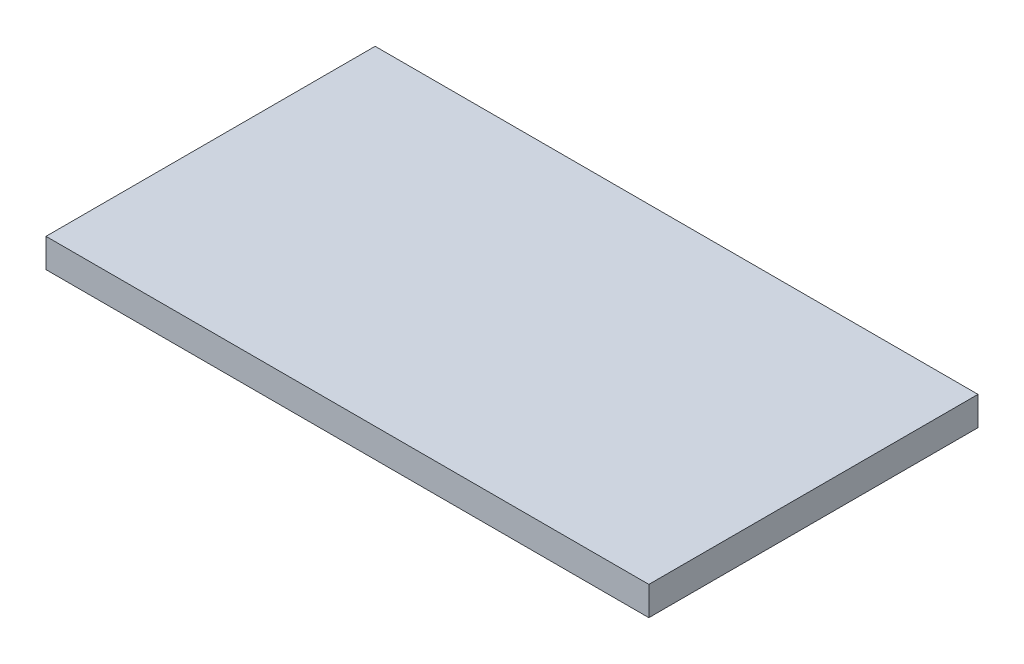
from build123d import *

# Parameters (mm, degrees)
SKETCH1_W           = 52.2
SKETCH1_H           = 28.5
SKETCH1_R           = 1
SKETCH1_W_2         = 35.320636832
SKETCH1_H_2         = 5.8
BOSS_EXTRUDE1_DEPTH = 2.5
SKETCH2_W           = 52.2
SKETCH2_H           = 28.5
BOSS_EXTRUDE2_DEPTH = 2.5


with BuildPart() as part:
    # Sketch1 → Boss-Extrude1 (new body)
    with BuildSketch(Plane(origin=(0, 0, 0), x_dir=(1, 0, 0), z_dir=(0, 1, 0))):
        with Locations((0, 2.55)):
            Rectangle(SKETCH1_W, SKETCH1_H)
        with Locations((-22.8, -3.2)):
            Circle(SKETCH1_R, mode=Mode.SUBTRACT)
        with Locations((22.8, -3.2)):
            Circle(SKETCH1_R, mode=Mode.SUBTRACT)
        with Locations((22.8, 8.3)):
            Circle(SKETCH1_R, mode=Mode.SUBTRACT)
        with Locations((-22.8, 8.3)):
            Circle(SKETCH1_R, mode=Mode.SUBTRACT)
        with Locations((0, -4.8)):
            Rectangle(SKETCH1_W_2, SKETCH1_H_2, mode=Mode.SUBTRACT)
        with Locations((0, 9.9)):
            Rectangle(SKETCH1_W_2, SKETCH1_H_2, mode=Mode.SUBTRACT)
    extrude(amount=BOSS_EXTRUDE1_DEPTH)

    # Sketch2 → Boss-Extrude2 (add)
    with BuildSketch(Plane.XZ):
        with Locations((0, -2.55)):
            Rectangle(SKETCH2_W, SKETCH2_H)
    extrude(amount=-BOSS_EXTRUDE2_DEPTH)


solid = part.part
